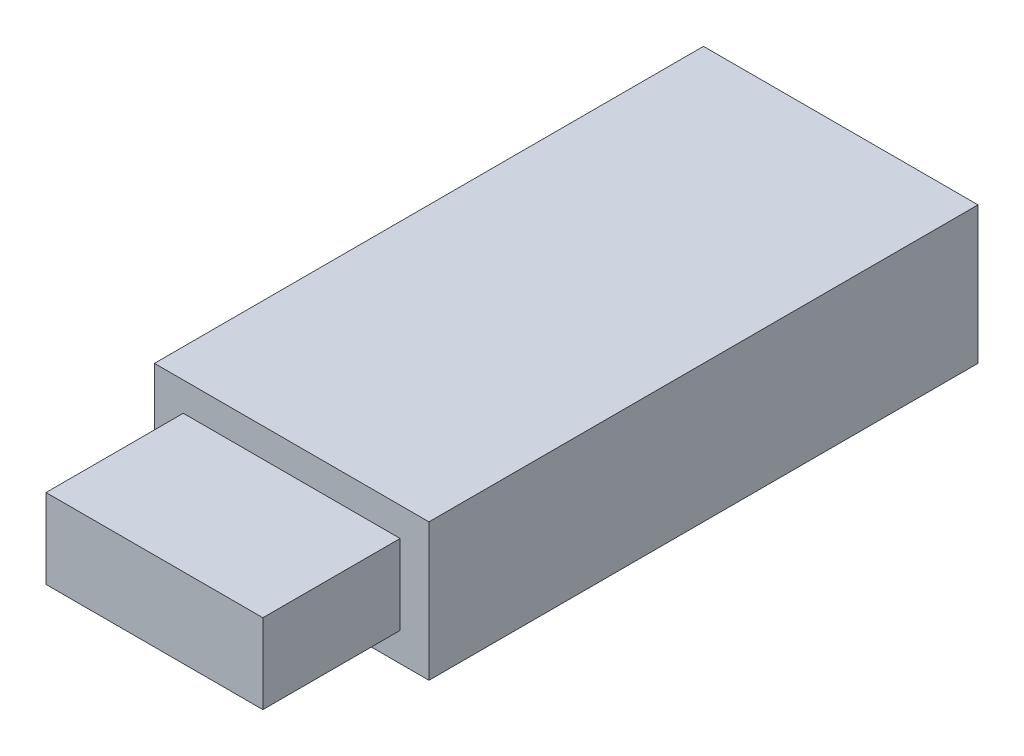
from build123d import *

# Parameters (mm, degrees)
SKETCH_3_W          = 40
SKETCH_3_H          = 20
EXTRUDE_3_DEPTH     = 100
SKETCH_4_W          = 40
SKETCH_4_H          = 20
SKETCH_4_W_2        = 31.6
SKETCH_4_H_2        = 11.6
CUT_EXTRUDE_1_DEPTH = 20


with BuildPart() as part:
    # 草图3 → 凸台-拉伸3 (new body)
    with BuildSketch(Plane.XY):
        Rectangle(SKETCH_3_W, SKETCH_3_H)
    extrude(amount=EXTRUDE_3_DEPTH)

    # 草图4 → 切除-拉伸1 (cut)
    with BuildSketch(Plane.XY.offset(100)):
        Rectangle(SKETCH_4_W, SKETCH_4_H)
        Rectangle(SKETCH_4_W_2, SKETCH_4_H_2, mode=Mode.SUBTRACT)
    extrude(amount=-CUT_EXTRUDE_1_DEPTH, mode=Mode.SUBTRACT)


solid = part.part
